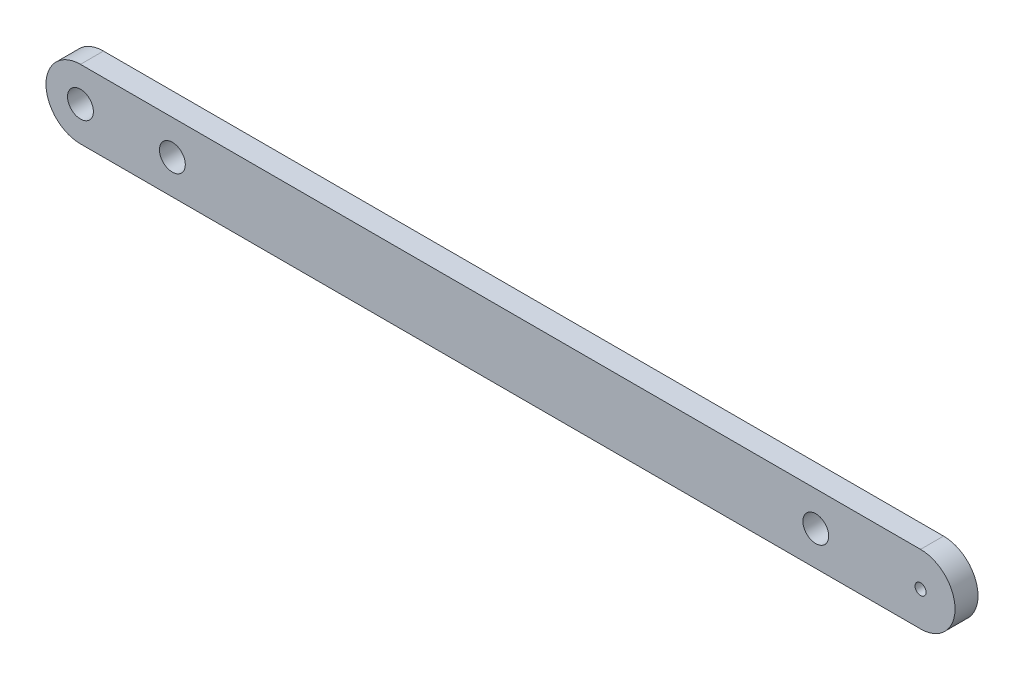
from build123d import *

# Parameters (mm, degrees)
SKETCH1_R                       = 0.762
BOSS_EXTRUDE1_DEPTH             = 3.175
F_9_64_0_14063_DIAMETER_HOLE1_D = 3.572002
F_9_64_0_14063_DIAMETER_HOLE2_D = 3.572002
F_9_64_0_14063_DIAMETER_HOLE3_D = 3.572002


with BuildPart() as part:
    # Sketch1 → Boss-Extrude1 (new body)
    with BuildSketch(Plane.XY):
        with BuildLine():
            Line((-10.922, -4.7625), (-127, -4.7625))
            ThreePointArc((-127, -4.7625), (-131.7625, 0), (-127, 4.7625))
            Line((-127, 4.7625), (-25.4, 4.7625))
            Line((-25.4, 4.7625), (-10.922, 4.7625))
            ThreePointArc((-10.922, 4.7625), (-6.1595, 0), (-10.922, -4.7625))
        make_face()
        with Locations((-25.4, 0)):
            Circle(SKETCH1_R, mode=Mode.SUBTRACT)
        with Locations((-10.922, 0)):
            Circle(SKETCH1_R, mode=Mode.SUBTRACT)
    extrude(amount=BOSS_EXTRUDE1_DEPTH)

    # 9/64 (0.14063) Diameter Hole1 (through all)
    with Locations(Plane.XY.offset(3.175)):
        with Locations((0, 0), (-127, 0)):
            Hole(F_9_64_0_14063_DIAMETER_HOLE1_D / 2)

    # 9/64 (0.14063) Diameter Hole2 (through all)
    with Locations(Plane.XY.offset(3.175)):
        with Locations((-114.3, 0)):
            Hole(F_9_64_0_14063_DIAMETER_HOLE2_D / 2)

    # 9/64 (0.14063) Diameter Hole3 (through all)
    with Locations(Plane.XY.offset(3.175)):
        with Locations((-25.4, 0)):
            Hole(F_9_64_0_14063_DIAMETER_HOLE3_D / 2)


solid = part.part
